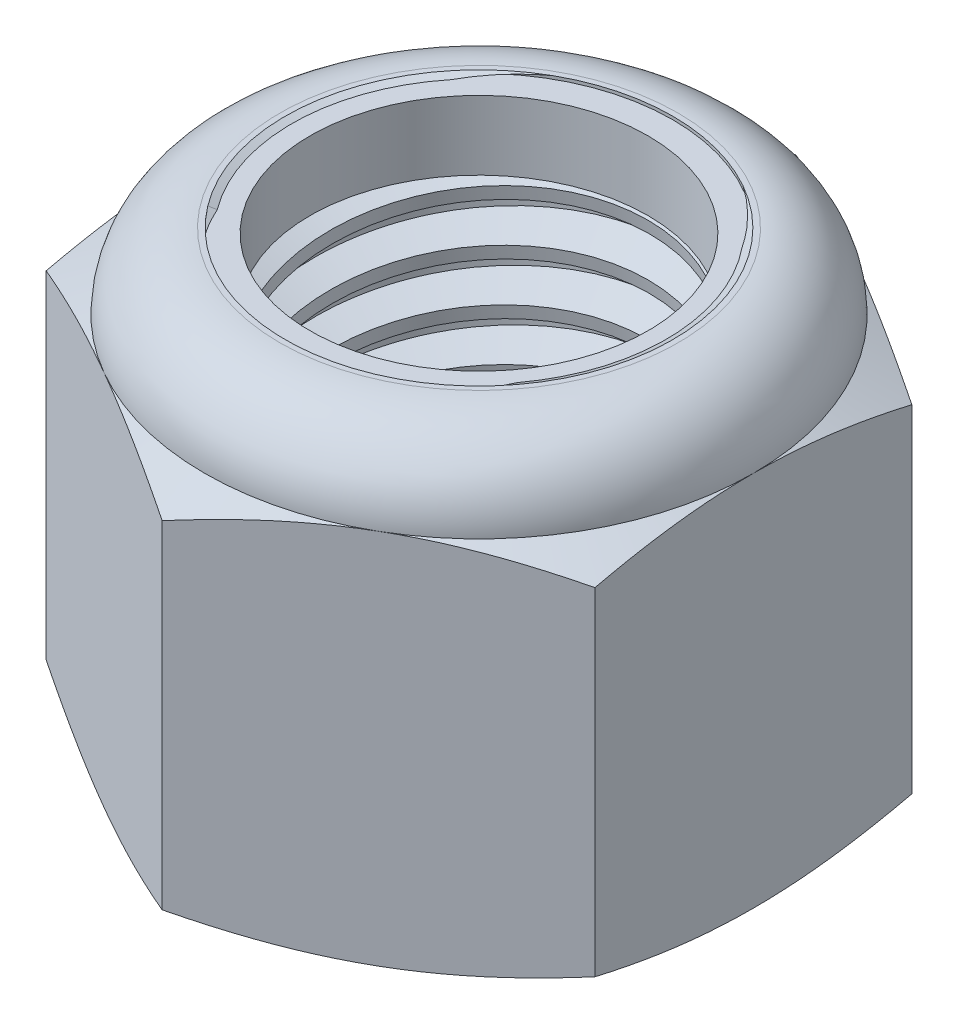
from build123d import *

# Parameters (mm, degrees)
EXTRUDE1_DEPTH      = 22.225
SKETCH2_W           = 9.525
SKETCH2_H           = 22.225
LPATTERN1_COUNT     = 9
LPATTERN1_PITCH     = 2.54
LPATTERN1_COL_COUNT = 2
LPATTERN1_COL_PITCH = 2.54


with BuildPart() as part:
    # Sketch1 → Extrude1 (new body)
    with BuildSketch(Plane(origin=(0, 0, 0), x_dir=(1, 0, 0), z_dir=(0, 1, 0))):
        Polygon((0, 15.58124039), (-13.49375, 7.790620195), (-13.49375, -7.790620195), (0, -15.58124039), (13.49375, -7.790620195), (13.49375, 7.790620195), align=None)
    extrude(amount=EXTRUDE1_DEPTH)

    # Sketch4 → Cut-Revolve2 (revolve, cut)
    with BuildSketch(Plane(origin=(0, 0, 0), x_dir=(0, 0, -1), z_dir=(1, 0, 0))):
        Polygon((0, 22.225), (9.525, 22.225), (8.309111622, 21.658021938), (8.309111622, 0.566978062), (9.525, 0), (0, 0), align=None)
    revolve(axis=Axis((0, 22.225, 0), (0, 1, 0)), mode=Mode.SUBTRACT)


with BuildPart() as body_2:
    # Sketch2 → Revolve1 (revolve)
    with BuildSketch(Plane(origin=(0, 0, 0), x_dir=(0, 0, -1), z_dir=(1, 0, 0))):
        with Locations((4.7625, 11.1125)):
            Rectangle(SKETCH2_W, SKETCH2_H)
    revolve(axis=Axis((0, -9.525, 0), (0, 1, 0)))

    # Sketch3 → Cut-Revolve1 (revolve, cut)
    with BuildSketch(Plane(origin=(0, 0, 0), x_dir=(0, 0, -1), z_dir=(1, 0, 0))):
        Polygon((9.566961981, 21.910285142), (9.860695849, 19.707281132), (8.393035584, 20.31236757), (8.309111622, 20.941797287), align=None)
    cut_revolve1 = revolve(axis=Axis((0, 22.225, 0.361519207), (0, -0.991227901, -0.13216372)), mode=Mode.SUBTRACT)

    # LPattern1: Cut-Revolve1 ×9
    with Locations(*[(0, -i * LPATTERN1_PITCH, 0) for i in range(1, LPATTERN1_COUNT)]):
        add(cut_revolve1, mode=Mode.SUBTRACT)

    # LPattern1 col: Cut-Revolve1 ×2
    with Locations(*[(0, i * LPATTERN1_COL_PITCH, 0) for i in range(1, LPATTERN1_COL_COUNT)]):
        add(cut_revolve1, mode=Mode.SUBTRACT)


with BuildPart() as part_1:
    add(part.part)

    # Combine1: cut body 2
    add(body_2.part, mode=Mode.SUBTRACT)

    # Sketch5 → Cut-Revolve3 (revolve, cut)
    with BuildSketch(Plane(origin=(0, 0, 0), x_dir=(0, 0, -1), z_dir=(1, 0, 0))):
        with BuildLine():
            Line((0, 0), (13.49375, 0))
            Line((13.49375, 0), (15.58124039, 0.973412755))
            Line((15.58124039, 0.973412755), (15.58124039, 17.547420578))
            Line((15.58124039, 17.547420578), (13.49375, 18.520833333))
            ThreePointArc((13.49375, 18.520833333), (12.408824702, 21.140074702), (9.789583333, 22.225))
            Line((9.789583333, 22.225), (9.789583333, 23.495))
            Line((9.789583333, 23.495), (16.85124039, 23.495))
            Line((16.85124039, 23.495), (16.85124039, -1.27))
            Line((16.85124039, -1.27), (0, -1.27))
            Line((0, -1.27), (0, 0))
        make_face()
    revolve(axis=Axis((0, 0, 0), (0, 1, 0)), mode=Mode.SUBTRACT)

    # Sketch6 → Cut-Revolve4 (revolve, cut)
    with BuildSketch(Plane(origin=(0, 0, 0), x_dir=(0, 0, -1), z_dir=(1, 0, 0))):
        with BuildLine():
            Line((0, 18.520833333), (13.34135, 18.520833333))
            ThreePointArc((13.34135, 18.520833333), (12.301061629, 21.032311629), (9.789583333, 22.0726))
            Line((9.789583333, 22.0726), (9.049347478, 22.0726))
            Line((9.049347478, 22.0726), (9.049347478, 23.495))
            Line((9.049347478, 23.495), (0, 23.495))
            Line((0, 23.495), (0, 18.520833333))
        make_face()
    revolve(axis=Axis((0, 23.495, 0), (0, 1, 0)), mode=Mode.SUBTRACT)


with BuildPart() as body_2_2:
    # Sketch7 → Revolve2 (revolve)
    with BuildSketch(Plane(origin=(0, 0, 0), x_dir=(0, 0, -1), z_dir=(1, 0, 0))):
        with BuildLine():
            Line((8.309111622, 18.597033333), (13.264314577, 18.597033333))
            ThreePointArc((13.264314577, 18.597033333), (12.220090017, 21.005224791), (9.789583333, 21.9964))
            Line((9.789583333, 21.9964), (8.309111622, 21.9964))
            Line((8.309111622, 21.9964), (8.309111622, 18.597033333))
        make_face()
    revolve(axis=Axis((0, 18.597033333, 0), (0, 1, 0)))


solid = Compound([part_1.part, body_2_2.part])
